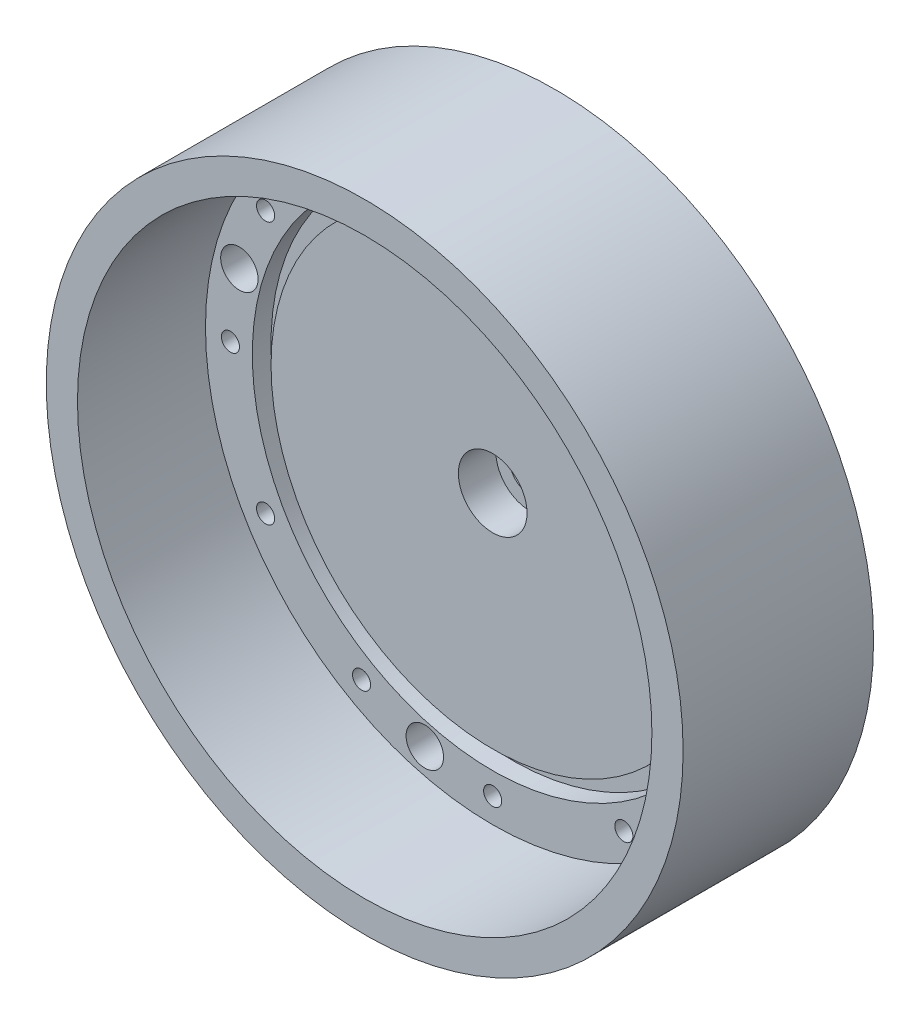
from build123d import *

# Parameters (mm, degrees)
SKETCH2_R                                       = 51
BOSS_EXTRUDE1_DEPTH                             = 30.5
SKETCH3_R                                       = 46
CUT_EXTRUDE1_DEPTH                              = 20.5
M3_5X0_6_TAPPED_HOLE1_D                         = 2.9
F_6_0MM_DOWEL_HOLE1_D                           = 6
SKETCH10_R                                      = 38.5
SKETCH10_R_2                                    = 35.5
CUT_EXTRUDE2_DEPTH                              = 3
CBORE_FOR_M6_SOCKET_HEAD_CAP_SCREW1_D           = 6.6
CBORE_FOR_M6_SOCKET_HEAD_CAP_SCREW1_CBORE_D     = 11
CBORE_FOR_M6_SOCKET_HEAD_CAP_SCREW1_CBORE_DEPTH = 6


with BuildPart() as part:
    # Sketch2 → Boss-Extrude1 (new body)
    with BuildSketch(Plane.XY):
        Circle(SKETCH2_R)
    extrude(amount=BOSS_EXTRUDE1_DEPTH)

    # Sketch3 → Cut-Extrude1 (cut)
    with BuildSketch(Plane.XY.offset(30.5)):
        Circle(SKETCH3_R)
    extrude(amount=-CUT_EXTRUDE1_DEPTH, mode=Mode.SUBTRACT)

    # M3.5x0.6 Tapped Hole1 (through all)
    with Locations(Plane(origin=(0, 0, 0), x_dir=(-1, 0, 0), z_dir=(0, 0, -1))):
        with Locations((21, 36.373066959), (36.373066959, 21), (42, 0), (36.373066959, -21), (21, -36.373066959), (0, -42), (-21, -36.373066959), (-36.373066959, -21), (-42, 0), (-36.373066959, 21), (-21, 36.373066959), (0, 42)):
            Hole(M3_5X0_6_TAPPED_HOLE1_D / 2)

    # Ø6.0mm Dowel Hole1 (through all)
    with Locations(Plane(origin=(0, 0, 0), x_dir=(-1, 0, 0), z_dir=(0, 0, -1))):
        with Locations((-10.870399894, 40.568884704), (40.568884704, 10.870399894), (10.870399894, -40.568884704), (-40.568884704, -10.870399894)):
            Hole(F_6_0MM_DOWEL_HOLE1_D / 2)

    # Sketch10 → Cut-Extrude2 (cut)
    with BuildSketch(Plane.XY.offset(10)):
        Circle(SKETCH10_R)
        Circle(SKETCH10_R_2, mode=Mode.SUBTRACT)
    extrude(amount=-CUT_EXTRUDE2_DEPTH, mode=Mode.SUBTRACT)

    # CBORE for M6 Socket Head Cap Screw1 (through all)
    with Locations(Plane.XY.offset(10)):
        with Locations((0, 0)):
            CounterBoreHole(CBORE_FOR_M6_SOCKET_HEAD_CAP_SCREW1_D / 2, CBORE_FOR_M6_SOCKET_HEAD_CAP_SCREW1_CBORE_D / 2, CBORE_FOR_M6_SOCKET_HEAD_CAP_SCREW1_CBORE_DEPTH)


solid = part.part
